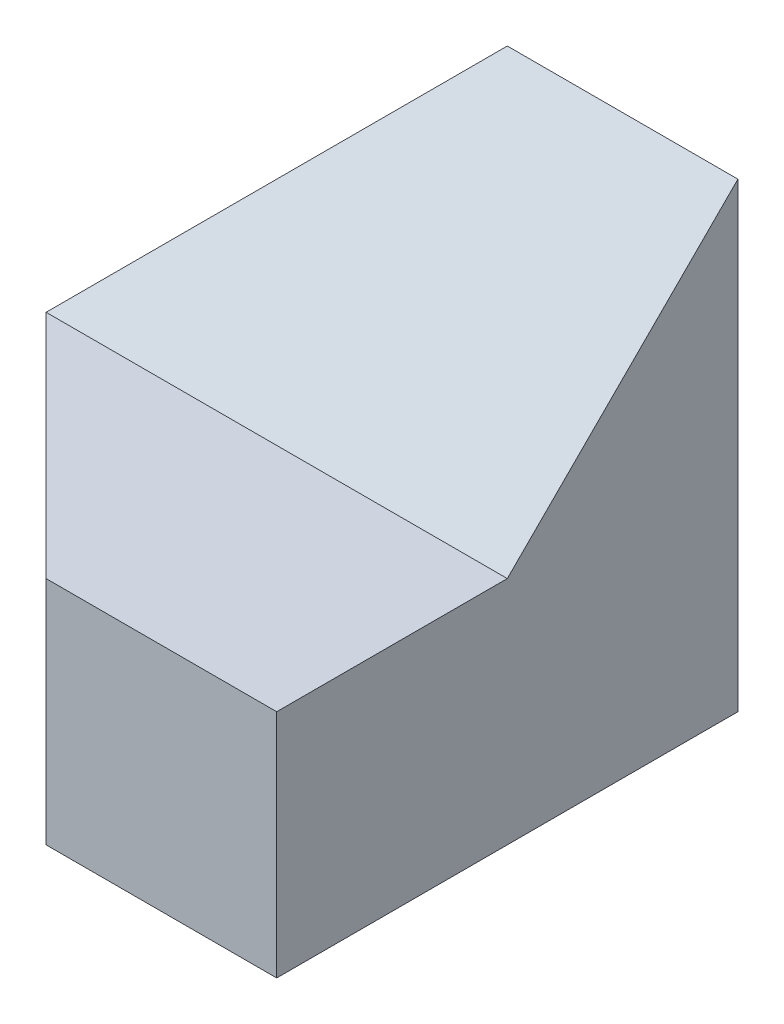
from build123d import *

# Parameters (mm, degrees)
SKETCH1_W           = 40
SKETCH1_H           = 40
BOSS_EXTRUDE1_DEPTH = 40
CUT_EXTRUDE1_DEPTH  = 40
CUT_EXTRUDE2_DEPTH  = 40
CUT_EXTRUDE3_DEPTH  = 40


with BuildPart() as part:
    # Sketch1 → Boss-Extrude1 (new body)
    with BuildSketch(Plane.XY):
        with Locations((20, 20)):
            Rectangle(SKETCH1_W, SKETCH1_H)
    extrude(amount=BOSS_EXTRUDE1_DEPTH)

    # Sketch2 → Cut-Extrude1 (cut)
    with BuildSketch(Plane.XY.offset(40)):
        Polygon((0, 20), (0, 40), (20, 40), align=None)
    extrude(amount=-CUT_EXTRUDE1_DEPTH, mode=Mode.SUBTRACT)

    # Sketch3 → Cut-Extrude2 (cut)
    with BuildSketch(Plane.ZY):
        Polygon((40, 20), (20, 20), (0, 40), (40, 40), align=None)
    extrude(amount=-CUT_EXTRUDE2_DEPTH, mode=Mode.SUBTRACT)

    # Sketch4 → Cut-Extrude3 (cut)
    with BuildSketch(Plane(origin=(0, 20, 0), x_dir=(1, 0, 0), z_dir=(0, 1, 0))):
        Polygon((0, -20), (20, -40), (0, -40), align=None)
    extrude(amount=-CUT_EXTRUDE3_DEPTH, mode=Mode.SUBTRACT)


solid = part.part
